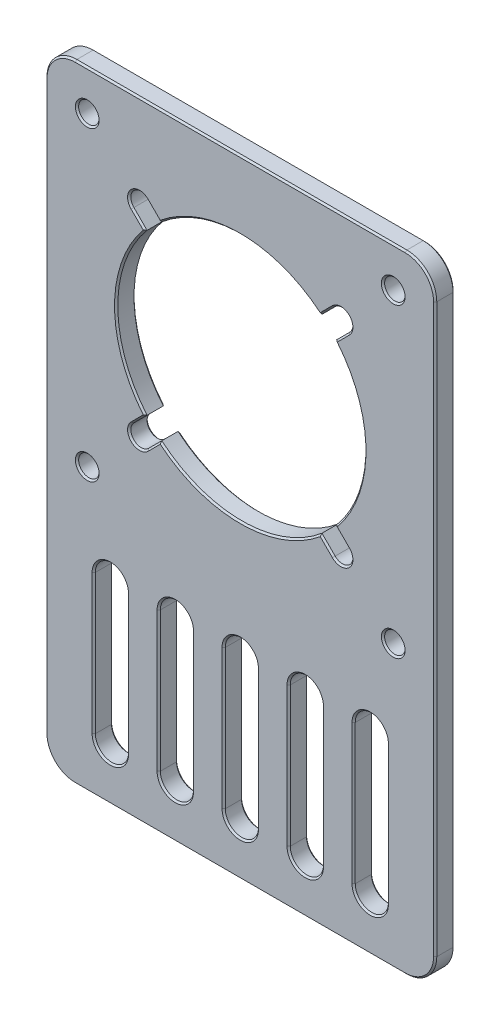
from build123d import *

# Parameters (mm, degrees)
EXTRUDE_1_DEPTH   = 3
HOLE_WIZARD_M31_D = 3.15
CHAMFER_2_SIZE    = 0.25


with BuildPart() as part:
    # Эскиз1 → Бобышка-Вытянуть1 (new body)
    with BuildSketch(Plane.XY):
        with BuildLine():
            Line((-25.4, -48.25), (25.4, -48.25))
            ThreePointArc((25.4, -48.25), (28.652691193, -46.902691193), (30, -43.65))
            Line((30, -43.65), (30, 43.65))
            ThreePointArc((30, 43.65), (28.652691193, 46.902691193), (25.4, 48.25))
            Line((25.4, 48.25), (-25.4, 48.25))
            ThreePointArc((-25.4, 48.25), (-28.652691193, 46.902691193), (-30, 43.65))
            Line((-30, 43.65), (-30, -43.65))
            ThreePointArc((-30, -43.65), (-28.652691193, -46.902691193), (-25.4, -48.25))
        make_face()
        with BuildLine():
            Line((-12.55, -40.2), (-12.55, -18.7))
            ThreePointArc((-12.55, -18.7), (-10, -16.15), (-7.45, -18.7))
            Line((-7.45, -18.7), (-7.45, -40.2))
            ThreePointArc((-7.45, -40.2), (-10, -42.75), (-12.55, -40.2))
        make_face(mode=Mode.SUBTRACT)
        with BuildLine():
            Line((-22.55, -40.2), (-22.55, -18.7))
            ThreePointArc((-22.55, -18.7), (-20, -16.15), (-17.45, -18.7))
            Line((-17.45, -18.7), (-17.45, -40.2))
            ThreePointArc((-17.45, -40.2), (-20, -42.75), (-22.55, -40.2))
        make_face(mode=Mode.SUBTRACT)
        with BuildLine():
            Line((-2.55, -40.2), (-2.55, -18.7))
            ThreePointArc((-2.55, -18.7), (0, -16.15), (2.55, -18.7))
            Line((2.55, -18.7), (2.55, -40.2))
            ThreePointArc((2.55, -40.2), (0, -42.75), (-2.55, -40.2))
        make_face(mode=Mode.SUBTRACT)
        with BuildLine():
            Line((7.45, -40.2), (7.45, -18.7))
            ThreePointArc((7.45, -18.7), (10, -16.15), (12.55, -18.7))
            Line((12.55, -18.7), (12.55, -40.2))
            ThreePointArc((12.55, -40.2), (10, -42.75), (7.45, -40.2))
        make_face(mode=Mode.SUBTRACT)
        with BuildLine():
            Line((17.45, -40.2), (17.45, -18.7))
            ThreePointArc((17.45, -18.7), (20, -16.15), (22.55, -18.7))
            Line((22.55, -18.7), (22.55, -40.2))
            ThreePointArc((22.55, -40.2), (20, -42.75), (17.45, -40.2))
        make_face(mode=Mode.SUBTRACT)
        with BuildLine():
            Line((-16.62137085, 32.90862915), (-14.589639684, 30.876897984))
            ThreePointArc((-14.589639684, 30.876897984), (-19.1, 18.55), (-14.589639684, 6.223102016))
            Line((-14.589639684, 6.223102016), (-16.62137085, 4.19137085))
            ThreePointArc((-16.62137085, 4.19137085), (-16.62137085, 1.92862915), (-14.35862915, 1.92862915))
            Line((-14.35862915, 1.92862915), (-12.326897984, 3.960360316))
            ThreePointArc((-12.326897984, 3.960360316), (0, -0.55), (12.326897984, 3.960360316))
            Line((12.326897984, 3.960360316), (14.35862915, 1.92862915))
            ThreePointArc((14.35862915, 1.92862915), (16.62137085, 1.92862915), (16.62137085, 4.19137085))
            Line((16.62137085, 4.19137085), (14.589639684, 6.223102016))
            ThreePointArc((14.589639684, 6.223102016), (19.1, 18.55), (14.589639684, 30.876897984))
            Line((14.589639684, 30.876897984), (16.62137085, 32.90862915))
            ThreePointArc((16.62137085, 32.90862915), (16.62137085, 35.17137085), (14.35862915, 35.17137085))
            Line((14.35862915, 35.17137085), (12.326897984, 33.139639684))
            ThreePointArc((12.326897984, 33.139639684), (0, 37.65), (-12.326897984, 33.139639684))
            Line((-12.326897984, 33.139639684), (-14.35862915, 35.17137085))
            ThreePointArc((-14.35862915, 35.17137085), (-16.62137085, 35.17137085), (-16.62137085, 32.90862915))
        make_face(mode=Mode.SUBTRACT)
    extrude(amount=EXTRUDE_1_DEPTH)

    # Сверло под метчик  спиральное M31 (through all)
    with Locations(Plane.XY.offset(3)):
        with Locations((-23.55, 42.1), (23.55, 42.1), (23.55, -5), (-23.55, -5)):
            Hole(HOLE_WIZARD_M31_D / 2)

    # Фаска2
    chamfer_2_edges = [part.edges().sort_by_distance(p)[0] for p in [
        (28.652691193, -46.902691193, 3),
        (0, -48.25, 0),
        (-28.652691193, -46.902691193, 0),
        (10, -16.15, 0),
        (7.45, -29.45, 0),
        (10, -42.75, 0),
        (12.55, -29.45, 0),
        (10, -16.15, 3),
        (7.45, -29.45, 3),
        (10, -42.75, 3),
        (12.55, -29.45, 3),
        (20, -16.15, 0),
        (17.45, -29.45, 0),
        (20, -42.75, 0),
        (22.55, -29.45, 0),
        (20, -16.15, 3),
        (17.45, -29.45, 3),
        (20, -42.75, 3),
        (22.55, -29.45, 3),
        (30, 0, 3),
        (-21.975, -5, 3),
        (-21.975, -5, 0),
        (25.125, -5, 3),
        (25.125, -5, 0),
        (25.125, 42.1, 3),
        (25.125, 42.1, 0),
        (28.652691193, 46.902691193, 3),
        (-21.975, 42.1, 3),
        (-21.975, 42.1, 0),
        (0, 48.25, 3),
        (-28.652691193, 46.902691193, 3),
        (-30, 0, 3),
        (19.1, 18.55, 0),
        (15.605505267, 31.892763567, 0),
        (16.62137085, 35.17137085, 0),
        (13.342763567, 34.155505267, 0),
        (0, 37.65, 0),
        (-13.342763567, 34.155505267, 0),
        (-16.62137085, 35.17137085, 0),
        (-15.605505267, 31.892763567, 0),
        (-19.1, 18.55, 0),
        (-15.605505267, 5.207236433, 0),
        (-16.62137085, 1.92862915, 0),
        (-13.342763567, 2.944494733, 0),
        (0, -0.55, 0),
        (13.342763567, 2.944494733, 0),
        (16.62137085, 1.92862915, 0),
        (15.605505267, 5.207236433, 0),
        (19.1, 18.55, 3),
        (15.605505267, 31.892763567, 3),
        (-28.652691193, -46.902691193, 3),
        (16.62137085, 35.17137085, 3),
        (13.342763567, 34.155505267, 3),
        (0, 37.65, 3),
        (-13.342763567, 34.155505267, 3),
        (-16.62137085, 35.17137085, 3),
        (-15.605505267, 31.892763567, 3),
        (-19.1, 18.55, 3),
        (-15.605505267, 5.207236433, 3),
        (-16.62137085, 1.92862915, 3),
        (-13.342763567, 2.944494733, 3),
        (0, -0.55, 3),
        (13.342763567, 2.944494733, 3),
        (16.62137085, 1.92862915, 3),
        (15.605505267, 5.207236433, 3),
        (-20, -16.15, 0),
        (-22.55, -29.45, 0),
        (-20, -42.75, 0),
        (0, -48.25, 3),
        (-17.45, -29.45, 0),
        (-20, -16.15, 3),
        (-22.55, -29.45, 3),
        (-20, -42.75, 3),
        (-17.45, -29.45, 3),
        (-30, 0, 0),
        (-28.652691193, 46.902691193, 0),
        (-10, -16.15, 0),
        (-12.55, -29.45, 0),
        (-10, -42.75, 0),
        (-7.45, -29.45, 0),
        (-10, -16.15, 3),
        (-12.55, -29.45, 3),
        (-10, -42.75, 3),
        (-7.45, -29.45, 3),
        (0, 48.25, 0),
        (28.652691193, 46.902691193, 0),
        (30, 0, 0),
        (0, -16.15, 0),
        (-2.55, -29.45, 0),
        (0, -42.75, 0),
        (2.55, -29.45, 0),
        (0, -16.15, 3),
        (-2.55, -29.45, 3),
        (28.652691193, -46.902691193, 0),
        (0, -42.75, 3),
        (2.55, -29.45, 3),
    ]]
    chamfer(chamfer_2_edges, length=CHAMFER_2_SIZE)


solid = part.part
